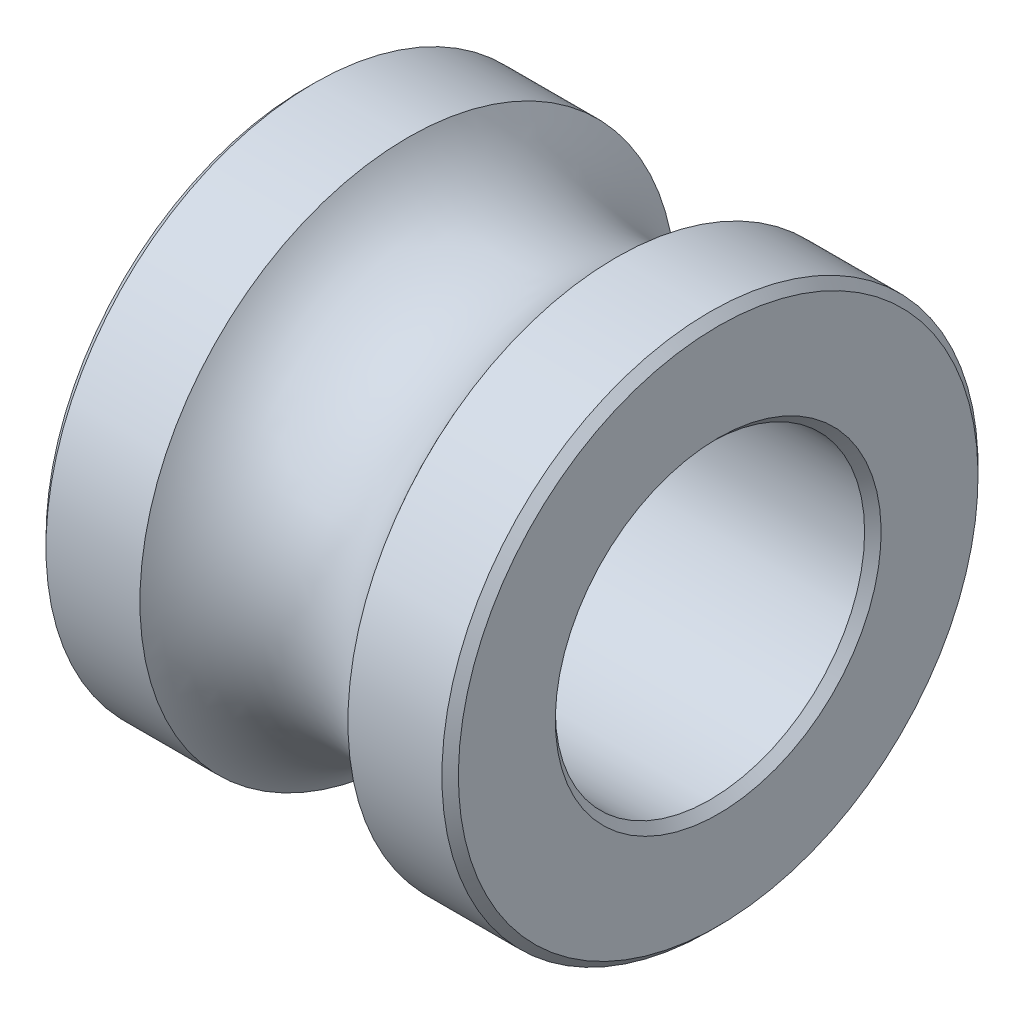
from build123d import *

# Parameters (mm, degrees)
CHAMFER1_SIZE = 0.08


with BuildPart() as part:
    # Sketch1 → Revolve1 (revolve)
    with BuildSketch(Plane.XY):
        with BuildLine():
            Line((-2, -1.5), (-2, -2.6))
            Line((-2, -2.6), (-1.00871205, -2.6))
            ThreePointArc((-1.00871205, -2.6), (0, -2.05), (1.00871205, -2.6))
            Line((1.00871205, -2.6), (2, -2.6))
            Line((2, -2.6), (2, -1.5))
            Line((2, -1.5), (-2, -1.5))
        make_face()
    revolve(axis=Axis((-6.429017492, 0, 0), (1, 0, 0)))

    # Chamfer1
    chamfer1_edges = [part.edges().sort_by_distance(p)[0] for p in [
        (-2, 1.5, 0),
        (-2, 2.6, 0),
        (2, 2.6, 0),
        (2, 1.5, 0),
    ]]
    chamfer(chamfer1_edges, length=CHAMFER1_SIZE)


solid = part.part
